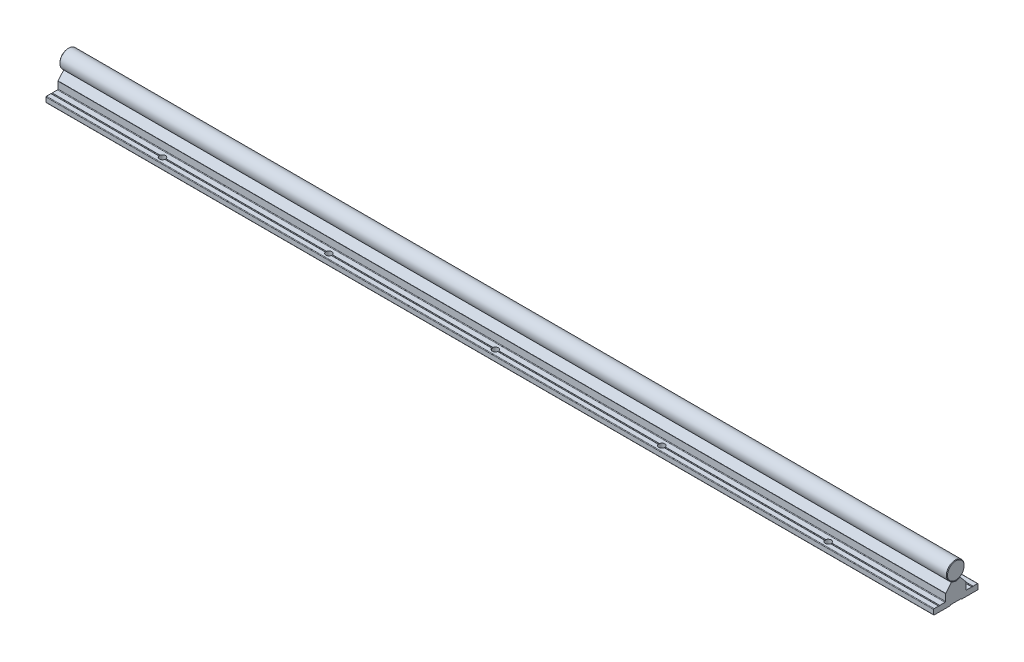
from build123d import *

# Parameters (mm, degrees)
EXTRUDE_4438_DEPTH       = 1500
SKETCH_1_3_R             = 8
EXTRUDE_4567_DEPTH       = 1500
FILLET_4_R               = 0.2
SKETCH_2_R               = 2.75
CUT_EXTRUDE_1_DEPTH      = 6
PATTERN_LINEAR_1_COUNT   = 20
PATTERN_LINEAR_1_PITCH   = 150
PATTERN_LINEAR_2_COUNT   = 20
PATTERN_LINEAR_2_PITCH   = 150
FILLET_1_R               = 0.3
CUT_EXTRUDE_2_DEPTH      = 3
FILLET_2_R               = 0.3
PATTERN_LINEAR_3_COUNT   = 20
PATTERN_LINEAR_3_PITCH   = 150
CHAMFER_1_SIZE           = 0.5
FILLET_3_R               = 0.5
FILLET_5_R               = 0.2
FILLET_6_R               = 0.1
FILLET_7_R               = 0.1
SKETCH_7_W               = 3500
SKETCH_7_H               = 1500
SKETCH_7_W_2             = 800
SKETCH_7_H_2             = 1000
CUT_EXTRUDE_3_DEPTH      = 9.0000001
CUT_EXTRUDE_3_DEPTH_BACK = 26.0000001
CHAMFER_2_SIZE           = 0.5


with BuildPart() as part:
    # Sketch 1 → Extrude 4438 (new body, symmetric)
    with BuildSketch(Plane(origin=(0, 0, 0), x_dir=(0, 0, -1), z_dir=(1, 0, 0))):
        Polygon((-20, -25), (-4.75, -25), (-4.75, -24.4), (4.75, -24.4), (4.75, -25), (20, -25), (20, -20), (15.5, -20), (15, -20.5), (14.5, -20), (9.25, -20), (9.25, -13.3), (9.110116754, -13.3), (4, -7.21), (3.8, -7.21), (2.309327639, -7.659439004), (0, -8.355703281), (-2.309327657, -7.659438999), (-3.8, -7.21), (-4, -7.21), (-9.110116754, -13.3), (-9.25, -13.3), (-9.25, -20), (-14.5, -20), (-15, -20.5), (-15.5, -20), (-20, -20), align=None)
    extrude(amount=EXTRUDE_4438_DEPTH, both=True)

    # Fillet 4
    fillet_4_edges = [part.edges().sort_by_distance(p)[0] for p in [
        (0, -20, -15.5),
        (0, -24.4, -4.75),
        (0, -24.4, 4.75),
        (0, -20, 15.5),
        (0, -20, 14.5),
        (0, -8.355703281, 0),
        (0, -20, -14.5),
    ]]
    fillet(fillet_4_edges, radius=FILLET_4_R)

    # Sketch 2 → Cut-Extrude 1 (cut, through all)
    with BuildSketch(Plane(origin=(0, -20, 0), x_dir=(1, 0, 0), z_dir=(0, 1, 0))):
        with Locations((-1425, -15)):
            Circle(SKETCH_2_R)
        with Locations((-1425, 15)):
            Circle(SKETCH_2_R)
        with Locations((-1275, -15)):
            Circle(SKETCH_2_R)
        with Locations((-1275, 15)):
            Circle(SKETCH_2_R)
        with Locations((-1125, -15)):
            Circle(SKETCH_2_R)
        with Locations((-1125, 15)):
            Circle(SKETCH_2_R)
        with Locations((-975, -15)):
            Circle(SKETCH_2_R)
        with Locations((-975, 15)):
            Circle(SKETCH_2_R)
        with Locations((-825, -15)):
            Circle(SKETCH_2_R)
        with Locations((-825, 15)):
            Circle(SKETCH_2_R)
        with Locations((-675, -15)):
            Circle(SKETCH_2_R)
        with Locations((-675, 15)):
            Circle(SKETCH_2_R)
        with Locations((-525, -15)):
            Circle(SKETCH_2_R)
        with Locations((-525, 15)):
            Circle(SKETCH_2_R)
        with Locations((-375, -15)):
            Circle(SKETCH_2_R)
        with Locations((-375, 15)):
            Circle(SKETCH_2_R)
        with Locations((-225, -15)):
            Circle(SKETCH_2_R)
        with Locations((-225, 15)):
            Circle(SKETCH_2_R)
        with Locations((-75, -15)):
            Circle(SKETCH_2_R)
        with Locations((-75, 15)):
            Circle(SKETCH_2_R)
        with Locations((75, -15)):
            Circle(SKETCH_2_R)
        with Locations((75, 15)):
            Circle(SKETCH_2_R)
        with Locations((225, -15)):
            Circle(SKETCH_2_R)
        with Locations((225, 15)):
            Circle(SKETCH_2_R)
        with Locations((375, -15)):
            Circle(SKETCH_2_R)
        with Locations((375, 15)):
            Circle(SKETCH_2_R)
        with Locations((525, -15)):
            Circle(SKETCH_2_R)
        with Locations((525, 15)):
            Circle(SKETCH_2_R)
        with Locations((675, -15)):
            Circle(SKETCH_2_R)
        with Locations((675, 15)):
            Circle(SKETCH_2_R)
        with Locations((825, -15)):
            Circle(SKETCH_2_R)
        with Locations((825, 15)):
            Circle(SKETCH_2_R)
        with Locations((975, -15)):
            Circle(SKETCH_2_R)
        with Locations((975, 15)):
            Circle(SKETCH_2_R)
        with Locations((1125, -15)):
            Circle(SKETCH_2_R)
        with Locations((1125, 15)):
            Circle(SKETCH_2_R)
        with Locations((1275, -15)):
            Circle(SKETCH_2_R)
        with Locations((1275, 15)):
            Circle(SKETCH_2_R)
        with Locations((1425, -15)):
            Circle(SKETCH_2_R)
        with Locations((1425, 15)):
            Circle(SKETCH_2_R)
    extrude(amount=-CUT_EXTRUDE_1_DEPTH, mode=Mode.SUBTRACT)

    # Sketch 3 → Cut-Revolve 1 (revolve, cut)
    with BuildSketch(Plane.XY):
        Polygon((-1425, 0), (-1427.2, -1.270170592), (-1427.2, -7.5), (-1427.75, -7.5), (-1427.75, -19), (-1429.75, -19), (-1429.75, -24.4), (-1425, -24.4), align=None)
    cut_revolve_1 = revolve(axis=Axis((-1425, 56.434869358, 0), (0, -1, 0)), mode=Mode.SUBTRACT)

    # Pattern Linear 1: Cut-Revolve 1 ×20
    with Locations(*[(i * PATTERN_LINEAR_1_PITCH, 0, 0) for i in range(1, PATTERN_LINEAR_1_COUNT)]):
        add(cut_revolve_1, mode=Mode.SUBTRACT)

    # Fillet 3
    fillet_3_edges = [part.edges().sort_by_distance(p)[0] for p in [
        (0, -20, -9.25),
        (0, -20, -20),
        (0, -25, -20),
        (0, -25, -4.75),
        (0, -25, 4.75),
        (0, -20, 9.25),
        (0, -25, 20),
        (0, -20, 20),
    ]]
    fillet(fillet_3_edges, radius=FILLET_3_R)

    # Fillet 5
    fillet_5_edges = [part.edges().sort_by_distance(p)[0] for p in [
        (0, -7.21, 4),
        (0, -7.21, 3.8),
        (0, -7.21, -3.8),
        (0, -7.21, -4),
    ]]
    fillet(fillet_5_edges, radius=FILLET_5_R)

    # Fillet 6
    fillet_6_edges = [part.edges().sort_by_distance(p)[0] for p in [
        (0, -13.3, 9.25),
        (0, -13.3, -9.25),
    ]]
    fillet(fillet_6_edges, radius=FILLET_6_R)

    # Fillet 7
    fillet_7_edges = [part.edges().sort_by_distance(p)[0] for p in [
        (0, -13.3, 9.110116754),
        (0, -13.3, -9.110116754),
    ]]
    fillet(fillet_7_edges, radius=FILLET_7_R)


with BuildPart() as body_2:
    # Sketch 1_3 → Extrude 4567 (new body, symmetric)
    with BuildSketch(Plane(origin=(0, 0, 0), x_dir=(0, 0, -1), z_dir=(1, 0, 0))):
        Circle(SKETCH_1_3_R)
    extrude(amount=EXTRUDE_4567_DEPTH, both=True)

    # Sketch 4 → Cut-Revolve 2 (revolve, cut)
    with BuildSketch(Plane.XY):
        Polygon((-1425, -10), (-1427.2, -10), (-1427.2, -1.270170592), (-1425, 0), align=None)
    cut_revolve_2 = revolve(axis=Axis((-1425, 39.840222878, 0), (0, -1, 0)), mode=Mode.SUBTRACT)

    # Pattern Linear 2: Cut-Revolve 2 ×20
    with Locations(*[(i * PATTERN_LINEAR_2_PITCH, 0, 0) for i in range(1, PATTERN_LINEAR_2_COUNT)]):
        add(cut_revolve_2, mode=Mode.SUBTRACT)

    # Chamfer 1
    chamfer_1_edges = [body_2.edges().sort_by_distance(p)[0] for p in [
        (-1500, 0, 8),
        (1500, 0, 8),
    ]]
    chamfer(chamfer_1_edges, length=CHAMFER_1_SIZE)


with BuildPart() as body_3:
    # Sketch 5 → Revolve 1 (revolve)
    with BuildSketch(Plane.XY):
        Polygon((-1425, -24), (-1429.5, -24), (-1429.5, -19), (-1427.5, -19), (-1427.5, -2.461880215), (-1426.7, -2), (-1425, -2), align=None)
    revolve(axis=Axis((-1425, 35.529626596, 0), (0, -1, 0)))

    # Fillet 1
    fillet_1_edges = [body_3.edges().sort_by_distance(p)[0] for p in [
        (-1420.5, -19, 0),
    ]]
    fillet(fillet_1_edges, radius=FILLET_1_R)

    # Sketch 6 → Cut-Extrude 2 (cut)
    with BuildSketch(Plane.XZ.offset(24)):
        Polygon((-1423.25, -1.010362971), (-1423.25, 1.010362971), (-1425, 2.020725942), (-1426.75, 1.010362971), (-1426.75, -1.010362971), (-1425, -2.020725942), align=None)
    extrude(amount=-CUT_EXTRUDE_2_DEPTH, mode=Mode.SUBTRACT)

    # Fillet 2
    fillet_2_edges = [body_3.edges().sort_by_distance(p)[0] for p in [
        (-1424.125, -24, -1.515544457),
        (-1423.25, -24, 0),
        (-1424.125, -24, 1.515544457),
        (-1425.875, -24, 1.515544457),
        (-1426.75, -24, 0),
        (-1425.875, -24, -1.515544457),
        (-1420.5, -24, 0),
    ]]
    fillet(fillet_2_edges, radius=FILLET_2_R)


with BuildPart() as pattern_linear_3_1:
    # Pattern Linear 3: pattern copy
    add(body_3.part.moved(Location(Vector(1, 0, 0) * (1 * PATTERN_LINEAR_3_PITCH))))


with BuildPart() as pattern_linear_3_2:
    # Pattern Linear 3: pattern copy
    add(body_3.part.moved(Location(Vector(1, 0, 0) * (2 * PATTERN_LINEAR_3_PITCH))))


with BuildPart() as pattern_linear_3_3:
    # Pattern Linear 3: pattern copy
    add(body_3.part.moved(Location(Vector(1, 0, 0) * (3 * PATTERN_LINEAR_3_PITCH))))


with BuildPart() as pattern_linear_3_4:
    # Pattern Linear 3: pattern copy
    add(body_3.part.moved(Location(Vector(1, 0, 0) * (4 * PATTERN_LINEAR_3_PITCH))))


with BuildPart() as pattern_linear_3_5:
    # Pattern Linear 3: pattern copy
    add(body_3.part.moved(Location(Vector(1, 0, 0) * (5 * PATTERN_LINEAR_3_PITCH))))


with BuildPart() as pattern_linear_3_6:
    # Pattern Linear 3: pattern copy
    add(body_3.part.moved(Location(Vector(1, 0, 0) * (6 * PATTERN_LINEAR_3_PITCH))))


with BuildPart() as pattern_linear_3_7:
    # Pattern Linear 3: pattern copy
    add(body_3.part.moved(Location(Vector(1, 0, 0) * (7 * PATTERN_LINEAR_3_PITCH))))


with BuildPart() as pattern_linear_3_8:
    # Pattern Linear 3: pattern copy
    add(body_3.part.moved(Location(Vector(1, 0, 0) * (8 * PATTERN_LINEAR_3_PITCH))))


with BuildPart() as pattern_linear_3_9:
    # Pattern Linear 3: pattern copy
    add(body_3.part.moved(Location(Vector(1, 0, 0) * (9 * PATTERN_LINEAR_3_PITCH))))


with BuildPart() as pattern_linear_3_10:
    # Pattern Linear 3: pattern copy
    add(body_3.part.moved(Location(Vector(1, 0, 0) * (10 * PATTERN_LINEAR_3_PITCH))))


with BuildPart() as pattern_linear_3_11:
    # Pattern Linear 3: pattern copy
    add(body_3.part.moved(Location(Vector(1, 0, 0) * (11 * PATTERN_LINEAR_3_PITCH))))


with BuildPart() as pattern_linear_3_12:
    # Pattern Linear 3: pattern copy
    add(body_3.part.moved(Location(Vector(1, 0, 0) * (12 * PATTERN_LINEAR_3_PITCH))))


with BuildPart() as pattern_linear_3_13:
    # Pattern Linear 3: pattern copy
    add(body_3.part.moved(Location(Vector(1, 0, 0) * (13 * PATTERN_LINEAR_3_PITCH))))


with BuildPart() as pattern_linear_3_14:
    # Pattern Linear 3: pattern copy
    add(body_3.part.moved(Location(Vector(1, 0, 0) * (14 * PATTERN_LINEAR_3_PITCH))))


with BuildPart() as pattern_linear_3_15:
    # Pattern Linear 3: pattern copy
    add(body_3.part.moved(Location(Vector(1, 0, 0) * (15 * PATTERN_LINEAR_3_PITCH))))


with BuildPart() as pattern_linear_3_16:
    # Pattern Linear 3: pattern copy
    add(body_3.part.moved(Location(Vector(1, 0, 0) * (16 * PATTERN_LINEAR_3_PITCH))))


with BuildPart() as pattern_linear_3_17:
    # Pattern Linear 3: pattern copy
    add(body_3.part.moved(Location(Vector(1, 0, 0) * (17 * PATTERN_LINEAR_3_PITCH))))


with BuildPart() as pattern_linear_3_18:
    # Pattern Linear 3: pattern copy
    add(body_3.part.moved(Location(Vector(1, 0, 0) * (18 * PATTERN_LINEAR_3_PITCH))))


with BuildPart() as pattern_linear_3_19:
    # Pattern Linear 3: pattern copy
    add(body_3.part.moved(Location(Vector(1, 0, 0) * (19 * PATTERN_LINEAR_3_PITCH))))


with BuildPart() as cut_extrude_3_tool:
    # Sketch 7 → Cut-Extrude 3 (new body, two sides)
    with BuildSketch(Plane(origin=(0, 0, 0), x_dir=(1, 0, 0), z_dir=(0, 1, 0))) as cut_extrude_3_sk:
        Rectangle(SKETCH_7_W, SKETCH_7_H)
        with Locations((75, 0)):
            Rectangle(SKETCH_7_W_2, SKETCH_7_H_2, mode=Mode.SUBTRACT)
    extrude(amount=CUT_EXTRUDE_3_DEPTH)
    extrude(cut_extrude_3_sk.sketch, amount=-CUT_EXTRUDE_3_DEPTH_BACK)


with BuildPart() as part_1:
    add(part.part)

    # Cut-Extrude 3: cut by cut_extrude_3_tool
    add(cut_extrude_3_tool.part, mode=Mode.SUBTRACT)


with BuildPart() as body_2_1:
    add(body_2.part)

    # Cut-Extrude 3: cut by cut_extrude_3_tool
    add(cut_extrude_3_tool.part, mode=Mode.SUBTRACT)

    # Chamfer 2
    chamfer_2_edges = [body_2_1.edges().sort_by_distance(p)[0] for p in [
        (-325, 0, 8),
        (475, 0, 8),
    ]]
    chamfer(chamfer_2_edges, length=CHAMFER_2_SIZE)


with BuildPart() as body_3_1:
    add(body_3.part)

    # Cut-Extrude 3: cut by cut_extrude_3_tool
    add(cut_extrude_3_tool.part, mode=Mode.SUBTRACT)


with BuildPart() as pattern_linear_3_1_1:
    add(pattern_linear_3_1.part)

    # Cut-Extrude 3: cut by cut_extrude_3_tool
    add(cut_extrude_3_tool.part, mode=Mode.SUBTRACT)


with BuildPart() as pattern_linear_3_2_1:
    add(pattern_linear_3_2.part)

    # Cut-Extrude 3: cut by cut_extrude_3_tool
    add(cut_extrude_3_tool.part, mode=Mode.SUBTRACT)


with BuildPart() as pattern_linear_3_3_1:
    add(pattern_linear_3_3.part)

    # Cut-Extrude 3: cut by cut_extrude_3_tool
    add(cut_extrude_3_tool.part, mode=Mode.SUBTRACT)


with BuildPart() as pattern_linear_3_4_1:
    add(pattern_linear_3_4.part)

    # Cut-Extrude 3: cut by cut_extrude_3_tool
    add(cut_extrude_3_tool.part, mode=Mode.SUBTRACT)


with BuildPart() as pattern_linear_3_5_1:
    add(pattern_linear_3_5.part)

    # Cut-Extrude 3: cut by cut_extrude_3_tool
    add(cut_extrude_3_tool.part, mode=Mode.SUBTRACT)


with BuildPart() as pattern_linear_3_6_1:
    add(pattern_linear_3_6.part)

    # Cut-Extrude 3: cut by cut_extrude_3_tool
    add(cut_extrude_3_tool.part, mode=Mode.SUBTRACT)


with BuildPart() as pattern_linear_3_7_1:
    add(pattern_linear_3_7.part)

    # Cut-Extrude 3: cut by cut_extrude_3_tool
    add(cut_extrude_3_tool.part, mode=Mode.SUBTRACT)


with BuildPart() as pattern_linear_3_13_1:
    add(pattern_linear_3_13.part)

    # Cut-Extrude 3: cut by cut_extrude_3_tool
    add(cut_extrude_3_tool.part, mode=Mode.SUBTRACT)


with BuildPart() as pattern_linear_3_14_1:
    add(pattern_linear_3_14.part)

    # Cut-Extrude 3: cut by cut_extrude_3_tool
    add(cut_extrude_3_tool.part, mode=Mode.SUBTRACT)


with BuildPart() as pattern_linear_3_15_1:
    add(pattern_linear_3_15.part)

    # Cut-Extrude 3: cut by cut_extrude_3_tool
    add(cut_extrude_3_tool.part, mode=Mode.SUBTRACT)


with BuildPart() as pattern_linear_3_16_1:
    add(pattern_linear_3_16.part)

    # Cut-Extrude 3: cut by cut_extrude_3_tool
    add(cut_extrude_3_tool.part, mode=Mode.SUBTRACT)


with BuildPart() as pattern_linear_3_17_1:
    add(pattern_linear_3_17.part)

    # Cut-Extrude 3: cut by cut_extrude_3_tool
    add(cut_extrude_3_tool.part, mode=Mode.SUBTRACT)


with BuildPart() as pattern_linear_3_18_1:
    add(pattern_linear_3_18.part)

    # Cut-Extrude 3: cut by cut_extrude_3_tool
    add(cut_extrude_3_tool.part, mode=Mode.SUBTRACT)


with BuildPart() as pattern_linear_3_19_1:
    add(pattern_linear_3_19.part)

    # Cut-Extrude 3: cut by cut_extrude_3_tool
    add(cut_extrude_3_tool.part, mode=Mode.SUBTRACT)


solid = Compound([pattern_linear_3_8.part, pattern_linear_3_9.part, pattern_linear_3_10.part, pattern_linear_3_11.part, pattern_linear_3_12.part, part_1.part, body_2_1.part])
